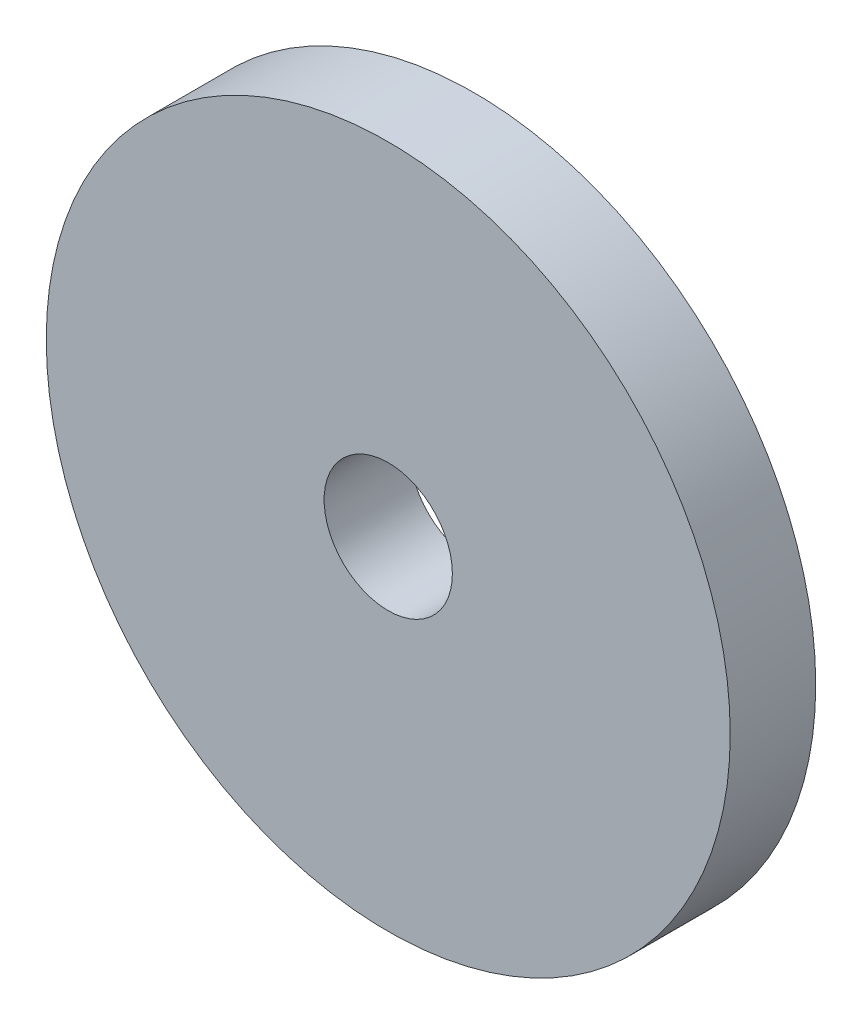
from build123d import *

# Parameters (mm, degrees)
SKETCH1_R           = 8
SKETCH1_R_2         = 1.5
BOSS_EXTRUDE1_DEPTH = 2


with BuildPart() as part:
    # Sketch1 → Boss-Extrude1 (new body)
    with BuildSketch(Plane.XY):
        Circle(SKETCH1_R)
        Circle(SKETCH1_R_2, mode=Mode.SUBTRACT)
    extrude(amount=BOSS_EXTRUDE1_DEPTH)


solid = part.part
